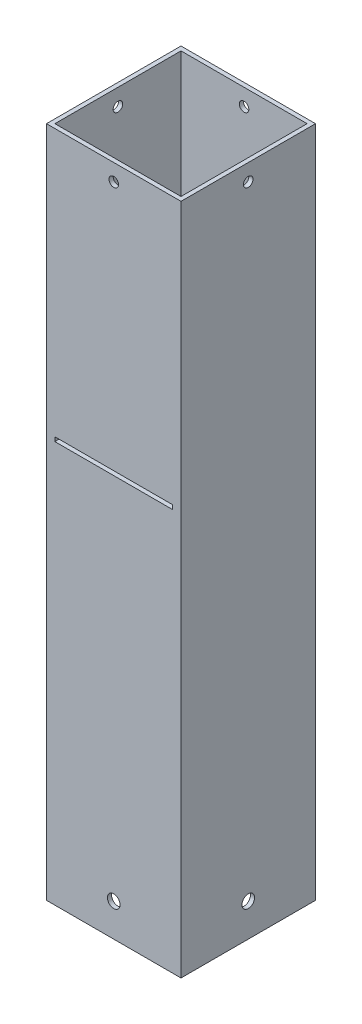
from build123d import *

# Parameters (mm, degrees)
SKETCH1_W               = 50.8
SKETCH1_H               = 50.8
SKETCH1_W_2             = 47.625
SKETCH1_H_2             = 47.625
BOSS_EXTRUDE1_DEPTH     = 254
SKETCH6_R               = 2.3999952
CUT_EXTRUDE3_DEPTH      = 1
CUT_EXTRUDE3_DEPTH_BACK = 51.8
SKETCH7_R               = 2.3999952
CUT_EXTRUDE4_DEPTH      = 1
CUT_EXTRUDE4_DEPTH_BACK = 51.8
SKETCH8_R               = 1.8034
CUT_EXTRUDE5_DEPTH      = 51.8
SKETCH9_R               = 1.8034
CUT_EXTRUDE6_DEPTH      = 51.8
SKETCH10_W              = 44.45
SKETCH10_H              = 1.5875
CUT_EXTRUDE7_DEPTH      = 51.8


with BuildPart() as part:
    # Sketch1 → Boss-Extrude1 (new body)
    with BuildSketch(Plane(origin=(0, 0, 0), x_dir=(1, 0, 0), z_dir=(0, 1, 0))):
        Rectangle(SKETCH1_W, SKETCH1_H)
        Rectangle(SKETCH1_W_2, SKETCH1_H_2, mode=Mode.SUBTRACT)
    extrude(amount=BOSS_EXTRUDE1_DEPTH)

    # Sketch6 → Cut-Extrude3 (cut, two sides)
    with BuildSketch(Plane(origin=(25.4, 0, 0), x_dir=(0, 0, -1), z_dir=(1, 0, 0))) as cut_extrude3_sk:
        with Locations((0, 12.412400118)):
            Circle(SKETCH6_R)
    extrude(amount=CUT_EXTRUDE3_DEPTH, mode=Mode.SUBTRACT)
    extrude(cut_extrude3_sk.sketch, amount=-CUT_EXTRUDE3_DEPTH_BACK, mode=Mode.SUBTRACT)

    # Sketch7 → Cut-Extrude4 (cut, two sides)
    with BuildSketch(Plane(origin=(0, 0, -25.4), x_dir=(-1, 0, 0), z_dir=(0, 0, -1))) as cut_extrude4_sk:
        with Locations((0, 12.412400118)):
            Circle(SKETCH7_R)
    extrude(amount=CUT_EXTRUDE4_DEPTH, mode=Mode.SUBTRACT)
    extrude(cut_extrude4_sk.sketch, amount=-CUT_EXTRUDE4_DEPTH_BACK, mode=Mode.SUBTRACT)

    # Sketch8 → Cut-Extrude5 (cut, through all)
    with BuildSketch(Plane(origin=(25.4, 0, 0), x_dir=(0, 0, -1), z_dir=(1, 0, 0))):
        with Locations((0, 247.65)):
            Circle(SKETCH8_R)
    extrude(amount=-CUT_EXTRUDE5_DEPTH, mode=Mode.SUBTRACT)

    # Sketch9 → Cut-Extrude6 (cut, through all)
    with BuildSketch(Plane.XY.offset(25.4)):
        with Locations((0, 247.65)):
            Circle(SKETCH9_R)
    extrude(amount=-CUT_EXTRUDE6_DEPTH, mode=Mode.SUBTRACT)

    # Sketch10 → Cut-Extrude7 (cut, through all)
    with BuildSketch(Plane.XY.offset(25.4)):
        with Locations((0, 152.4)):
            Rectangle(SKETCH10_W, SKETCH10_H)
    extrude(amount=-CUT_EXTRUDE7_DEPTH, mode=Mode.SUBTRACT)


solid = part.part
